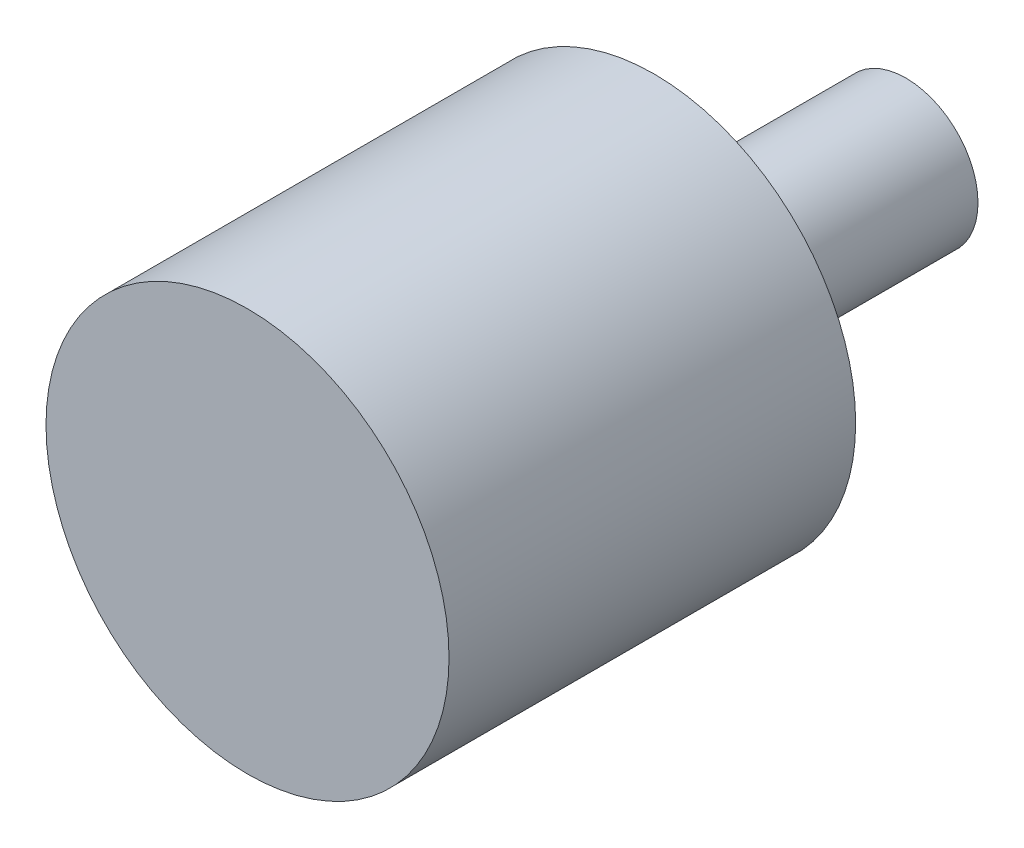
from build123d import *

# Parameters (mm, degrees)
SKETCH1_R           = 28
SKETCH1_R_2         = 26
BOSS_EXTRUDE1_DEPTH = 55
SKETCH2_R           = 28
BOSS_EXTRUDE2_DEPTH = 1.5
SKETCH3_R           = 10
BOSS_EXTRUDE3_DEPTH = 90


with BuildPart() as part:
    # Sketch1 → Boss-Extrude1 (new body)
    with BuildSketch(Plane.XY):
        Circle(SKETCH1_R)
        Circle(SKETCH1_R_2, mode=Mode.SUBTRACT)
    extrude(amount=BOSS_EXTRUDE1_DEPTH)

    # Sketch2 → Boss-Extrude2 (add)
    with BuildSketch(Plane.XY.offset(55)):
        Circle(SKETCH2_R)
    extrude(amount=BOSS_EXTRUDE2_DEPTH)

    # Sketch3 → Boss-Extrude3 (add)
    with BuildSketch(Plane(origin=(0, 0, 55), x_dir=(-1, 0, 0), z_dir=(0, 0, -1))):
        Circle(SKETCH3_R)
    extrude(amount=BOSS_EXTRUDE3_DEPTH)


solid = part.part
